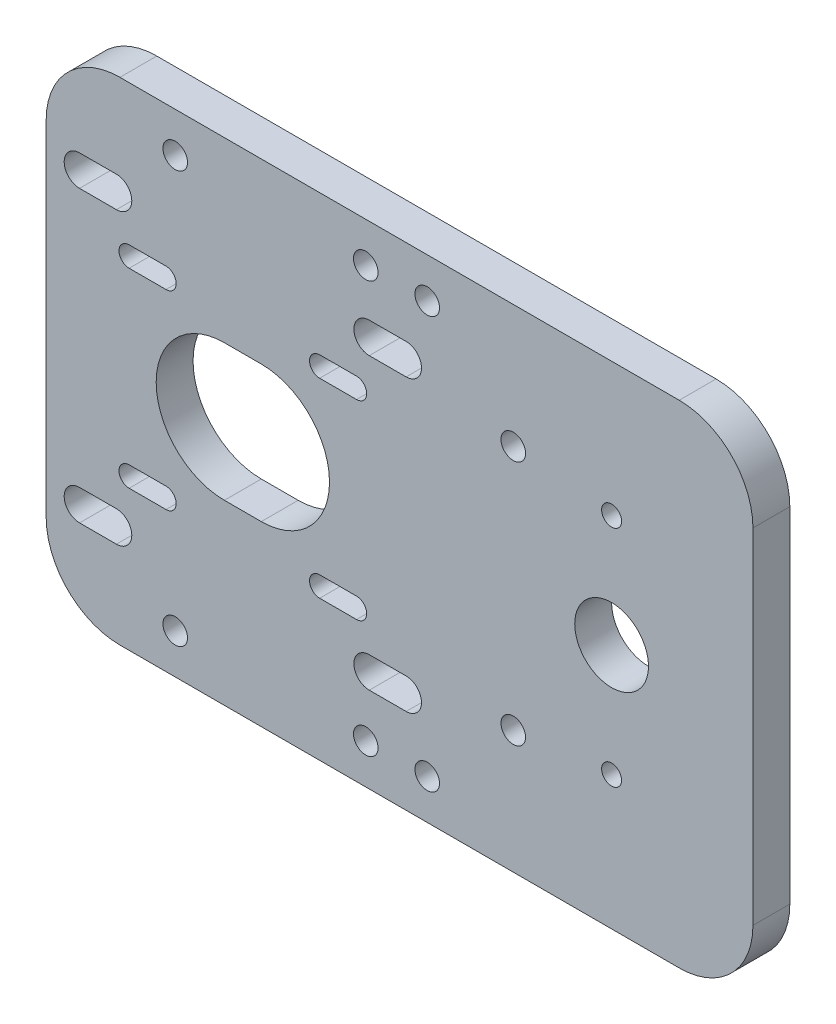
from build123d import *

# Parameters (mm, degrees)
CROQUIS1_W              = 115
CROQUIS1_H              = 80
SALIENTE_EXTRUIR1_DEPTH = 6
CROQUIS2_R              = 6
CROQUIS2_R_2            = 1.625
CROQUIS2_R_3            = 2
CORTAR_EXTRUIR1_DEPTH   = 7
REDONDEO1_R             = 12
CROQUIS3_R              = 2
CORTAR_EXTRUIR2_DEPTH   = 7


with BuildPart() as part:
    # Croquis1 → Saliente-Extruir1 (new body)
    with BuildSketch(Plane.XY):
        with Locations((57.5, 40)):
            Rectangle(CROQUIS1_W, CROQUIS1_H)
    extrude(amount=SALIENTE_EXTRUIR1_DEPTH)

    # Croquis2 → Cortar-Extruir1 (cut, through all)
    with BuildSketch(Plane(origin=(0, 0, 0), x_dir=(-1, 0, 0), z_dir=(0, 0, -1))):
        with Locations((-92, 40)):
            Circle(CROQUIS2_R)
        with Locations((-92, 21.75)):
            Circle(CROQUIS2_R_2)
        with Locations((-92, 58.25)):
            Circle(CROQUIS2_R_2)
        with Locations((-76, 20)):
            Circle(CROQUIS2_R_3)
        with Locations((-76, 60)):
            Circle(CROQUIS2_R_3)
        with BuildLine():
            Line((-29, 28.9), (-35, 28.9))
            ThreePointArc((-35, 28.9), (-46.1, 40), (-35, 51.1))
            Line((-35, 51.1), (-29, 51.1))
            ThreePointArc((-29, 51.1), (-17.9, 40), (-29, 28.9))
        make_face()
        with BuildLine():
            Line((-13.5, 22.85), (-19.5, 22.85))
            ThreePointArc((-19.5, 22.85), (-21.15, 24.5), (-19.5, 26.15))
            Line((-19.5, 26.15), (-13.5, 26.15))
            ThreePointArc((-13.5, 26.15), (-11.85, 24.5), (-13.5, 22.85))
        make_face()
        with BuildLine():
            Line((-44.5, 53.85), (-50.5, 53.85))
            ThreePointArc((-50.5, 53.85), (-52.15, 55.5), (-50.5, 57.15))
            Line((-50.5, 57.15), (-44.5, 57.15))
            ThreePointArc((-44.5, 57.15), (-42.85, 55.5), (-44.5, 53.85))
        make_face()
        with BuildLine():
            Line((-44.5, 22.85), (-50.5, 22.85))
            ThreePointArc((-50.5, 22.85), (-52.15, 24.5), (-50.5, 26.15))
            Line((-50.5, 26.15), (-44.5, 26.15))
            ThreePointArc((-44.5, 26.15), (-42.85, 24.5), (-44.5, 22.85))
        make_face()
        with BuildLine():
            Line((-13.5, 53.85), (-19.5, 53.85))
            ThreePointArc((-19.5, 53.85), (-21.15, 55.5), (-19.5, 57.15))
            Line((-19.5, 57.15), (-13.5, 57.15))
            ThreePointArc((-13.5, 57.15), (-11.85, 55.5), (-13.5, 53.85))
        make_face()
        with BuildLine():
            Line((-52.57, 13.93), (-58.57, 13.93))
            ThreePointArc((-58.57, 13.93), (-61.07, 16.43), (-58.57, 18.93))
            Line((-58.57, 18.93), (-52.57, 18.93))
            ThreePointArc((-52.57, 18.93), (-50.07, 16.43), (-52.57, 13.93))
        make_face()
        with BuildLine():
            Line((-5.43, 13.93), (-11.43, 13.93))
            ThreePointArc((-11.43, 13.93), (-13.93, 16.43), (-11.43, 18.93))
            Line((-11.43, 18.93), (-5.43, 18.93))
            ThreePointArc((-5.43, 18.93), (-2.93, 16.43), (-5.43, 13.93))
        make_face()
        with BuildLine():
            Line((-52.57, 61.07), (-58.57, 61.07))
            ThreePointArc((-58.57, 61.07), (-61.07, 63.57), (-58.57, 66.07))
            Line((-58.57, 66.07), (-52.57, 66.07))
            ThreePointArc((-52.57, 66.07), (-50.07, 63.57), (-52.57, 61.07))
        make_face()
        with BuildLine():
            Line((-5.43, 61.07), (-11.43, 61.07))
            ThreePointArc((-11.43, 61.07), (-13.93, 63.57), (-11.43, 66.07))
            Line((-11.43, 66.07), (-5.43, 66.07))
            ThreePointArc((-5.43, 66.07), (-2.93, 63.57), (-5.43, 61.07))
        make_face()
    extrude(amount=-CORTAR_EXTRUIR1_DEPTH, mode=Mode.SUBTRACT)

    # Redondeo1
    redondeo1_edges = [part.edges().sort_by_distance(p)[0] for p in [
        (0, 80, 3),
        (115, 80, 3),
        (115, 0, 3),
        (0, 0, 3),
    ]]
    fillet(redondeo1_edges, radius=REDONDEO1_R)

    # Croquis3 → Cortar-Extruir2 (cut, through all)
    with BuildSketch(Plane(origin=(0, 0, 0), x_dir=(-1, 0, 0), z_dir=(0, 0, -1))):
        with Locations((-21, 6.5)):
            Circle(CROQUIS3_R)
        with Locations((-62, 6.5)):
            Circle(CROQUIS3_R)
        with Locations((-62, 73.5)):
            Circle(CROQUIS3_R)
        with Locations((-21, 73.5)):
            Circle(CROQUIS3_R)
        with Locations((-52, 6.5)):
            Circle(CROQUIS3_R)
        with Locations((-52, 73.5)):
            Circle(CROQUIS3_R)
    extrude(amount=-CORTAR_EXTRUIR2_DEPTH, mode=Mode.SUBTRACT)


solid = part.part
